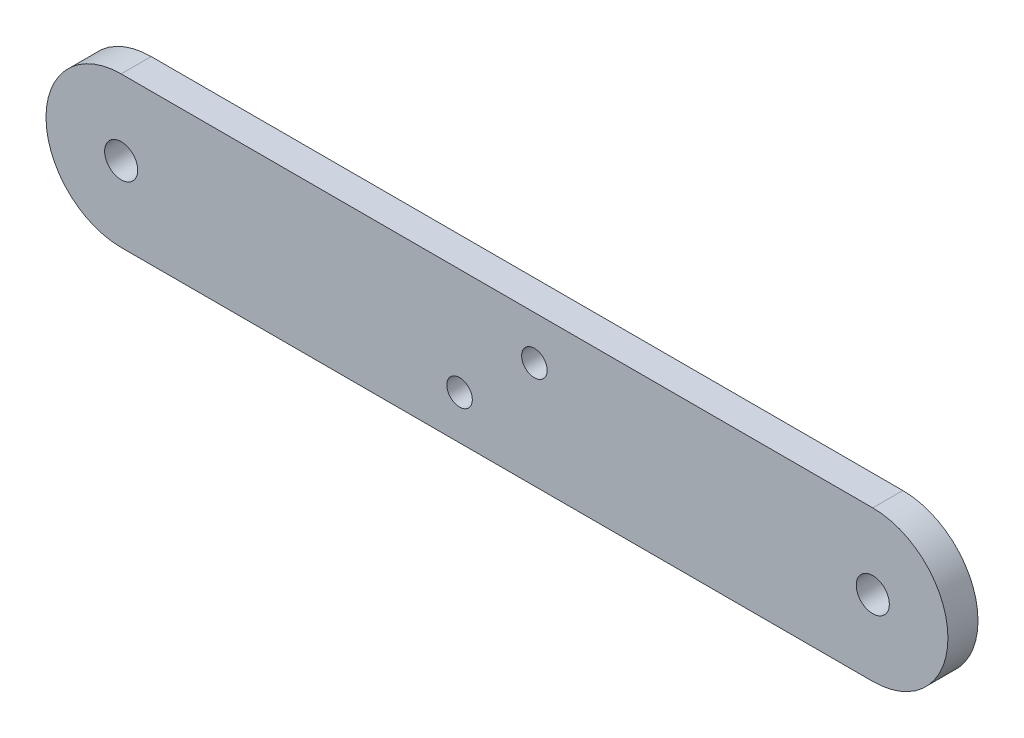
from build123d import *

# Parameters (mm, degrees)
ESQUISSE1_R        = 2.2
ESQUISSE1_R_2      = 1.7
BOSS_EXTRU_1_DEPTH = 4


with BuildPart() as part:
    # Esquisse1 → Boss.-Extru.1 (new body)
    with BuildSketch(Plane.XY):
        with BuildLine():
            Line((0, 10), (100, 10))
            ThreePointArc((100, 10), (110, 0), (100, -10))
            Line((100, -10), (0, -10))
            ThreePointArc((0, -10), (-10, 0), (0, 10))
        make_face()
        Circle(ESQUISSE1_R, mode=Mode.SUBTRACT)
        with Locations((100, 0)):
            Circle(ESQUISSE1_R, mode=Mode.SUBTRACT)
        with Locations((54.97928888, 4.178119463)):
            Circle(ESQUISSE1_R_2, mode=Mode.SUBTRACT)
        with Locations((45.02071112, -4.178119463)):
            Circle(ESQUISSE1_R_2, mode=Mode.SUBTRACT)
    extrude(amount=BOSS_EXTRU_1_DEPTH)


solid = part.part
